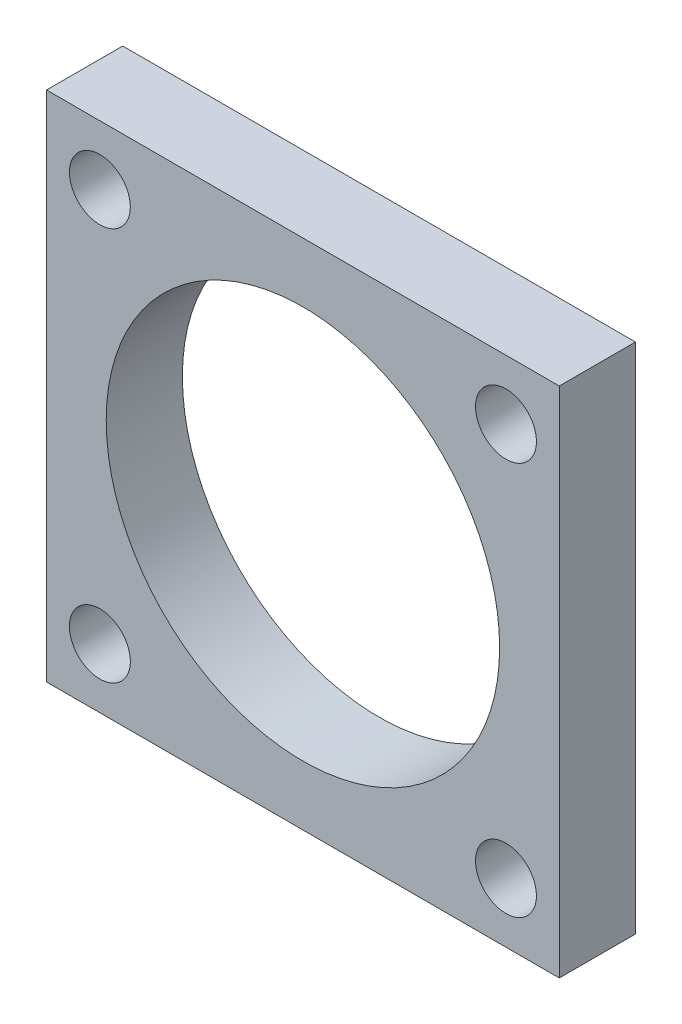
from build123d import *

# Parameters (mm, degrees)
SKETCH1_W           = 20.2
SKETCH1_H           = 20.2
SKETCH1_R           = 7.75
SKETCH1_R_2         = 1.2
BOSS_EXTRUDE2_DEPTH = 3


with BuildPart() as part:
    # Sketch1 → Boss-Extrude2 (new body)
    with BuildSketch(Plane.XY):
        with Locations((-1.544211534, -0.533070866)):
            Rectangle(SKETCH1_W, SKETCH1_H)
        with Locations((-1.544211534, -0.533070866)):
            Circle(SKETCH1_R, mode=Mode.SUBTRACT)
        with Locations((-9.544211534, 7.216929134)):
            Circle(SKETCH1_R_2, mode=Mode.SUBTRACT)
        with Locations((6.455788466, 7.216929134)):
            Circle(SKETCH1_R_2, mode=Mode.SUBTRACT)
        with Locations((-9.544211534, -8.283070866)):
            Circle(SKETCH1_R_2, mode=Mode.SUBTRACT)
        with Locations((6.455788466, -8.283070866)):
            Circle(SKETCH1_R_2, mode=Mode.SUBTRACT)
    extrude(amount=BOSS_EXTRUDE2_DEPTH)


solid = part.part
